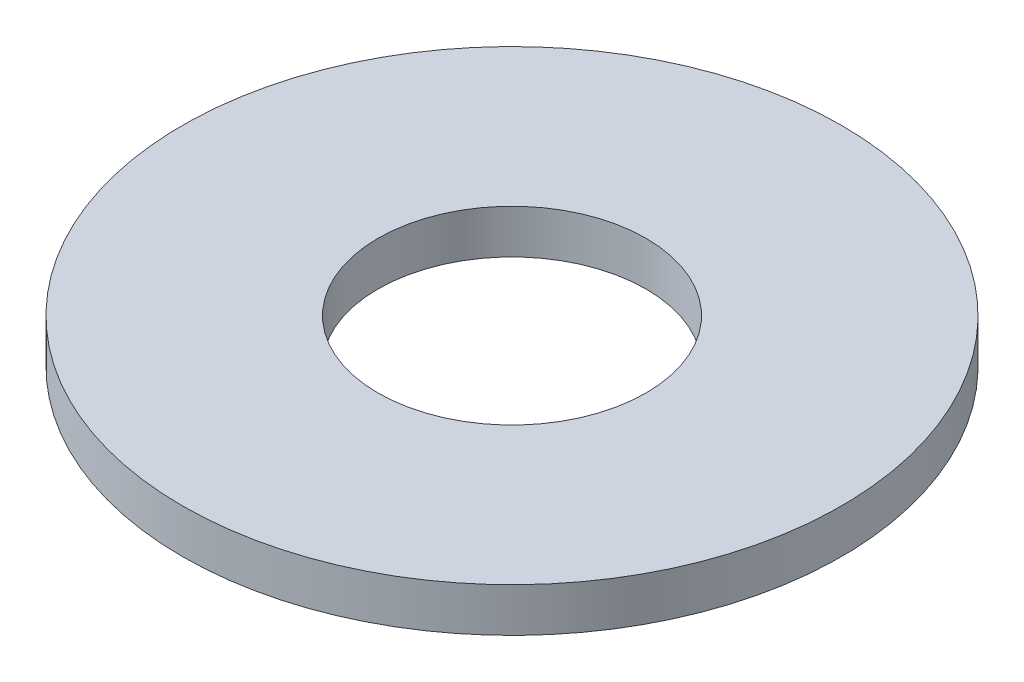
from build123d import *

# Parameters (mm, degrees)
SKETCH1_R           = 7.5
SKETCH1_R_2         = 3.05
BOSS_EXTRUDE1_DEPTH = 1


with BuildPart() as part:
    # Sketch1 → Boss-Extrude1 (new body)
    with BuildSketch(Plane(origin=(0, 0, 0), x_dir=(1, 0, 0), z_dir=(0, 1, 0))):
        Circle(SKETCH1_R)
        Circle(SKETCH1_R_2, mode=Mode.SUBTRACT)
    extrude(amount=BOSS_EXTRUDE1_DEPTH)


solid = part.part
